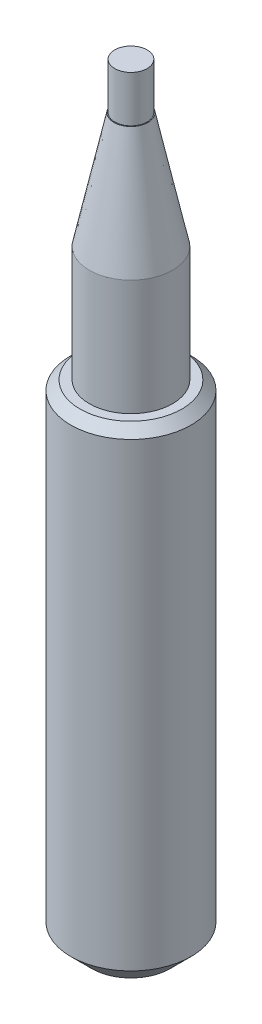
from build123d import *

# Parameters (mm, degrees)
SKETCH1_R           = 9
BOSS_EXTRUDE1_DEPTH = 50
SKETCH1_3_R         = 13
BOSS_EXTRUDE2_DEPTH = 106
SKETCH2_R           = 3.5
BOSS_EXTRUDE3_DEPTH = 10
CHAMFER1_SIZE       = 4.5
CHAMFER2_SIZE       = 25
CHAMFER2_SIZE2      = 5.313914042
SKETCH3_R           = 1
CUT_EXTRUDE1_DEPTH  = 10
CHAMFER3_SIZE       = 2


with BuildPart() as part:
    # Sketch1 → Boss-Extrude1 (new body)
    with BuildSketch(Plane(origin=(0, 0, 0), x_dir=(1, 0, 0), z_dir=(0, 1, 0))):
        Circle(SKETCH1_R)
    extrude(amount=BOSS_EXTRUDE1_DEPTH)

    # Sketch1_3 → Boss-Extrude2 (add)
    with BuildSketch(Plane(origin=(0, 0, 0), x_dir=(1, 0, 0), z_dir=(0, 1, 0))):
        Circle(SKETCH1_3_R)
    extrude(amount=-BOSS_EXTRUDE2_DEPTH)

    # Sketch2 → Boss-Extrude3 (add)
    with BuildSketch(Plane(origin=(0, 50, 0), x_dir=(1, 0, 0), z_dir=(0, 1, 0))):
        Circle(SKETCH2_R)
    extrude(amount=BOSS_EXTRUDE3_DEPTH)

    # Chamfer1
    chamfer1_edges = [part.edges().sort_by_distance(p)[0] for p in [
        (-13, -106, 0),
    ]]
    chamfer(chamfer1_edges, length=CHAMFER1_SIZE)

    # Chamfer2
    chamfer2_edges = [part.edges().sort_by_distance(p)[0] for p in [
        (-9, 50, 0),
    ]]
    chamfer2_side = [part.faces().sort_by_distance(p)[0] for p in [
        (-9, 25, 0),
    ]]
    chamfer(chamfer2_edges, length=CHAMFER2_SIZE, length2=CHAMFER2_SIZE2, reference=chamfer2_side[0])

    # Sketch3 → Cut-Extrude1 (cut)
    with BuildSketch(Plane.XZ.offset(106)):
        with Locations((0, 10)):
            Circle(SKETCH3_R)
        with Locations((10, 0)):
            Circle(SKETCH3_R)
        with Locations((0, -10)):
            Circle(SKETCH3_R)
        with Locations((-10, 0)):
            Circle(SKETCH3_R)
    extrude(amount=-CUT_EXTRUDE1_DEPTH, mode=Mode.SUBTRACT)

    # Chamfer3
    chamfer3_edges = [part.edges().sort_by_distance(p)[0] for p in [
        (-13, 0, 0),
    ]]
    chamfer(chamfer3_edges, length=CHAMFER3_SIZE)


solid = part.part
